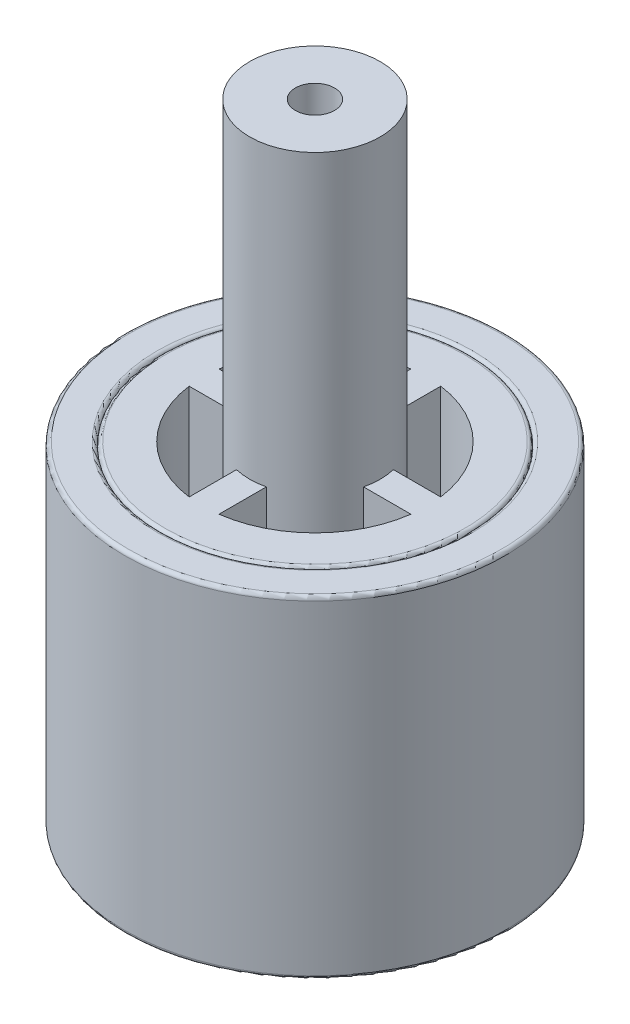
from build123d import *

# Parameters (mm, degrees)
SKETCH_1_R          = 4.125
EXTRUDE_1_DEPTH     = 8.9
SKETCH_2_R          = 1.75
EXTRUDE_2_DEPTH     = 7.95
CUT_EXTRUDE_1_DEPTH = 3
CUT_EXTRUDE_2_DEPTH = 3
SKETCH_5_R          = 0.525
CUT_EXTRUDE_3_DEPTH = 16.85
SKETCH_6_R          = 5.1
SKETCH_6_R_2        = 4.125
EXTRUDE_3_DEPTH     = 8.9
FILLET_1_R          = 0.1
FILLET_2_R          = 0.1


with BuildPart() as part:
    # Эскиз1 → Бобышка-Вытянуть1 (new body)
    with BuildSketch(Plane(origin=(0, 0, 0), x_dir=(1, 0, 0), z_dir=(0, 1, 0))):
        Circle(SKETCH_1_R)
    extrude(amount=EXTRUDE_1_DEPTH)

    # Эскиз2 → Бобышка-Вытянуть2 (add)
    with BuildSketch(Plane(origin=(0, 8.9, 0), x_dir=(1, 0, 0), z_dir=(0, 1, 0))):
        Circle(SKETCH_2_R)
    extrude(amount=EXTRUDE_2_DEPTH)

    # Эскиз3 → Вырез-Вытянуть1 (cut)
    with BuildSketch(Plane(origin=(0, 8.9, 0), x_dir=(1, 0, 0), z_dir=(0, 1, 0))):
        with BuildLine():
            Line((-0.4, 2.973214), (-0.4, 1.703673))
            ThreePointArc((-0.4, 1.703673), (-1.237437, 1.237437), (-1.703673, 0.4))
            Line((-1.703673, 0.4), (-2.973214, 0.4))
            ThreePointArc((-2.973214, 0.4), (-2.12132, 2.12132), (-0.4, 2.973214))
        make_face()
        with BuildLine():
            Line((-2.973214, -0.4), (-1.703673, -0.4))
            ThreePointArc((-1.703673, -0.4), (-1.237437, -1.237437), (-0.4, -1.703673))
            Line((-0.4, -1.703673), (-0.4, -2.973214))
            ThreePointArc((-0.4, -2.973214), (-2.12132, -2.12132), (-2.973214, -0.4))
        make_face()
        with BuildLine():
            Line((0.4, 2.973214), (0.4, 1.703673))
            ThreePointArc((0.4, 1.703673), (1.237437, 1.237437), (1.703673, 0.4))
            Line((1.703673, 0.4), (2.973214, 0.4))
            ThreePointArc((2.973214, 0.4), (2.12132, 2.12132), (0.4, 2.973214))
        make_face()
        with BuildLine():
            Line((1.703673, -0.4), (2.973214, -0.4))
            ThreePointArc((2.973214, -0.4), (2.12132, -2.12132), (0.4, -2.973214))
            Line((0.4, -2.973214), (0.4, -1.703673))
            ThreePointArc((0.4, -1.703673), (1.237437, -1.237437), (1.703673, -0.4))
        make_face()
    extrude(amount=-CUT_EXTRUDE_1_DEPTH, mode=Mode.SUBTRACT)

    # Эскиз4 → Вырез-Вытянуть2 (cut)
    with BuildSketch(Plane.XZ):
        with BuildLine():
            Line((0.4, -1.703673), (0.4, -2.973214))
            ThreePointArc((0.4, -2.973214), (2.12132, -2.12132), (2.973214, -0.4))
            Line((2.973214, -0.4), (1.703673, -0.4))
            ThreePointArc((1.703673, -0.4), (1.237437, -1.237437), (0.4, -1.703673))
        make_face()
        with BuildLine():
            Line((0.4, 2.973214), (0.4, 1.703673))
            ThreePointArc((0.4, 1.703673), (1.237437, 1.237437), (1.703673, 0.4))
            Line((1.703673, 0.4), (2.973214, 0.4))
            ThreePointArc((2.973214, 0.4), (2.12132, 2.12132), (0.4, 2.973214))
        make_face()
        with BuildLine():
            Line((-2.973214, 0.4), (-1.703673, 0.4))
            ThreePointArc((-1.703673, 0.4), (-1.237437, 1.237437), (-0.4, 1.703673))
            Line((-0.4, 1.703673), (-0.4, 2.973214))
            ThreePointArc((-0.4, 2.973214), (-2.12132, 2.12132), (-2.973214, 0.4))
        make_face()
        with BuildLine():
            Line((-1.703673, -0.4), (-2.973214, -0.4))
            ThreePointArc((-2.973214, -0.4), (-2.12132, -2.12132), (-0.4, -2.973214))
            Line((-0.4, -2.973214), (-0.4, -1.703673))
            ThreePointArc((-0.4, -1.703673), (-1.237437, -1.237437), (-1.703673, -0.4))
        make_face()
    extrude(amount=-CUT_EXTRUDE_2_DEPTH, mode=Mode.SUBTRACT)

    # Эскиз5 → Вырез-Вытянуть3 (cut)
    with BuildSketch(Plane.XZ):
        Circle(SKETCH_5_R)
    extrude(amount=-CUT_EXTRUDE_3_DEPTH, mode=Mode.SUBTRACT)

    # Скругление2
    fillet_2_edges = [part.edges().sort_by_distance(p)[0] for p in [
        (-4.125, 0, 0),
        (-4.125, 8.9, 0),
    ]]
    fillet(fillet_2_edges, radius=FILLET_2_R)


with BuildPart() as body_2:
    # Эскиз6 → Бобышка-Вытянуть3 (new body)
    with BuildSketch(Plane(origin=(0, 8.9, 0), x_dir=(1, 0, 0), z_dir=(0, 1, 0))):
        Circle(SKETCH_6_R)
        Circle(SKETCH_6_R_2, mode=Mode.SUBTRACT)
    extrude(amount=-EXTRUDE_3_DEPTH)

    # Скругление1
    fillet_1_edges = [body_2.edges().sort_by_distance(p)[0] for p in [
        (-5.1, 8.9, 0),
        (-4.125, 8.9, 0),
        (-5.1, 0, 0),
        (-4.125, 0, 0),
    ]]
    fillet(fillet_1_edges, radius=FILLET_1_R)


solid = Compound([part.part, body_2.part])
